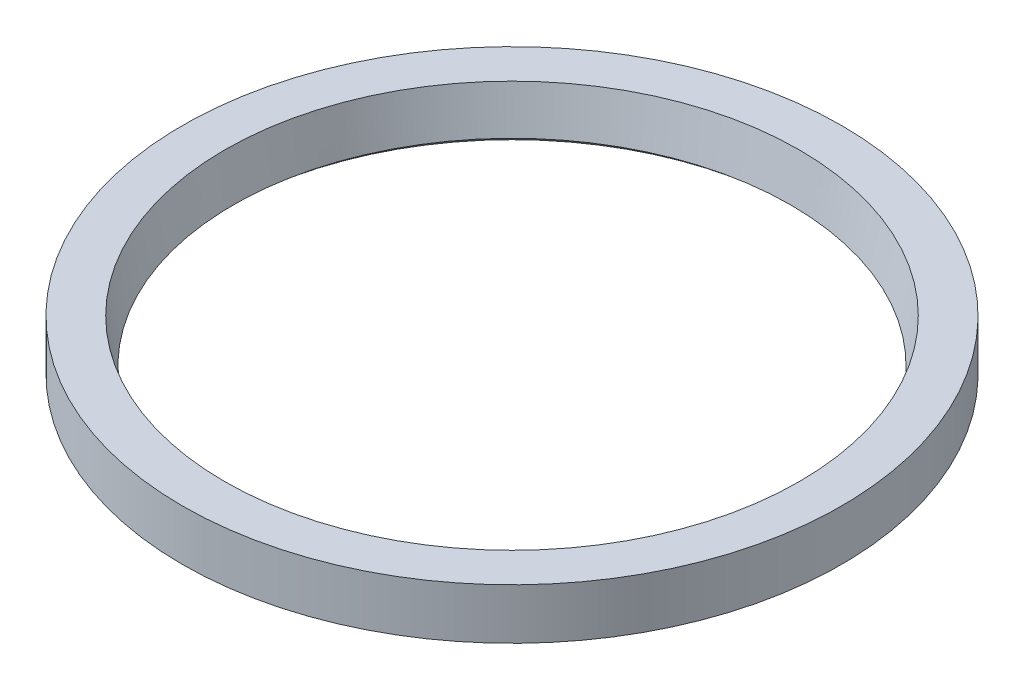
from build123d import *


with BuildPart() as part:
    # Schizzo1 → Rivoluzione1 (revolve)
    with BuildSketch(Plane.XY):
        Polygon((17, 0), (19.5, 0), (19.5, 3), (17, 3), (16.488701215, 0.434794773), align=None)
    revolve(axis=Axis((0, 0, 0), (0, 1, 0)))


solid = part.part
